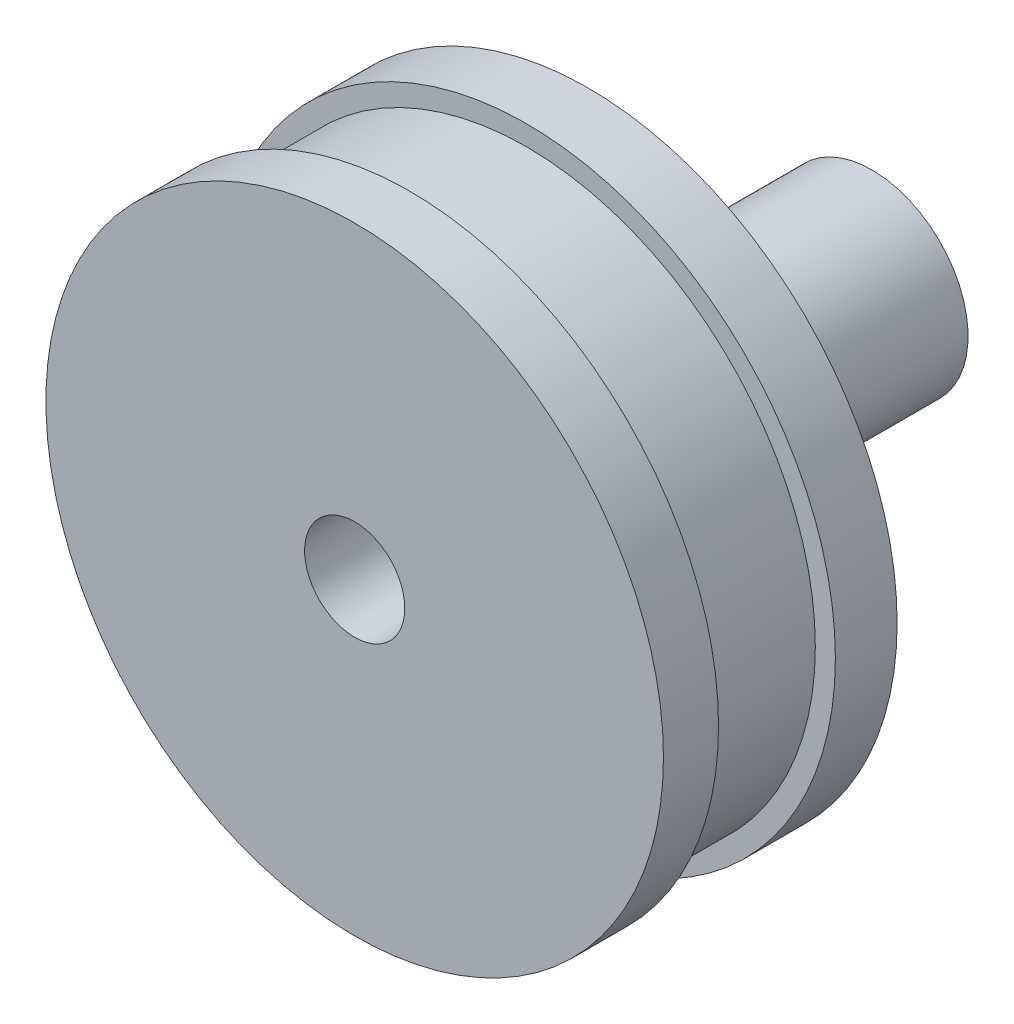
from build123d import *

# Parameters (mm, degrees)
SKETCH_1_R          = 18.5
SKETCH_1_R_2        = 3
EXTRUDE_1_DEPTH     = 14
CUT_EXTRUDE_START   = -2.2
SKETCH_2_R          = 18.5
SKETCH_2_R_2        = 17.3
CUT_EXTRUDE_1_DEPTH = 2.2
SKETCH_2_2_R        = 18.5
SKETCH_2_2_R_2      = 17.3
CUT_EXTRUDE_2_DEPTH = 0.8
CUT_EXTRUDE_START_2 = -4
SKETCH_2_4_R        = 18.5
SKETCH_2_4_R_2      = 17.3
CUT_EXTRUDE_3_DEPTH = 4
SKETCH_2_6_R        = 18.5
SKETCH_2_6_R_2      = 17.3
CUT_EXTRUDE_5_DEPTH = 3
SKETCH_3_R          = 7
EXTRUDE_3_DEPTH     = 5
SKETCH_4_R          = 5.75
EXTRUDE_4_DEPTH     = 12


with BuildPart() as part:
    # 草图1 → 凸台-拉伸1 (new body)
    with BuildSketch(Plane.XY):
        Circle(SKETCH_1_R)
        Circle(SKETCH_1_R_2, mode=Mode.SUBTRACT)
    extrude(amount=EXTRUDE_1_DEPTH)

    # 草图2 → 切除-拉伸1 (cut)
    with BuildSketch(Plane.XY.offset(7.7).offset(CUT_EXTRUDE_START)):
        Circle(SKETCH_2_R)
        Circle(SKETCH_2_R_2, mode=Mode.SUBTRACT)
    extrude(amount=CUT_EXTRUDE_1_DEPTH, mode=Mode.SUBTRACT)

    # 草图2<2> → 切除-拉伸2 (cut)
    with BuildSketch(Plane.XY.offset(7.7)):
        Circle(SKETCH_2_2_R)
        Circle(SKETCH_2_2_R_2, mode=Mode.SUBTRACT)
    extrude(amount=CUT_EXTRUDE_2_DEPTH, mode=Mode.SUBTRACT)

    # 草图2<4> → 切除-拉伸3 (cut)
    with BuildSketch(Plane.XY.offset(7.7).offset(CUT_EXTRUDE_START_2)):
        Circle(SKETCH_2_4_R)
        Circle(SKETCH_2_4_R_2, mode=Mode.SUBTRACT)
    extrude(amount=CUT_EXTRUDE_3_DEPTH, mode=Mode.SUBTRACT)

    # 草图2<6> → 切除-拉伸5 (cut)
    with BuildSketch(Plane.XY.offset(7.7)):
        Circle(SKETCH_2_6_R)
        Circle(SKETCH_2_6_R_2, mode=Mode.SUBTRACT)
    extrude(amount=CUT_EXTRUDE_5_DEPTH, mode=Mode.SUBTRACT)

    # 草图3 → 凸台-拉伸3 (add)
    with BuildSketch(Plane(origin=(0, 0, 0), x_dir=(-1, 0, 0), z_dir=(0, 0, -1))):
        Circle(SKETCH_3_R)
    extrude(amount=EXTRUDE_3_DEPTH)

    # 草图4 → 凸台-拉伸4 (add)
    with BuildSketch(Plane(origin=(0, 0, -5), x_dir=(-1, 0, 0), z_dir=(0, 0, -1))):
        Circle(SKETCH_4_R)
    extrude(amount=EXTRUDE_4_DEPTH)


solid = part.part
